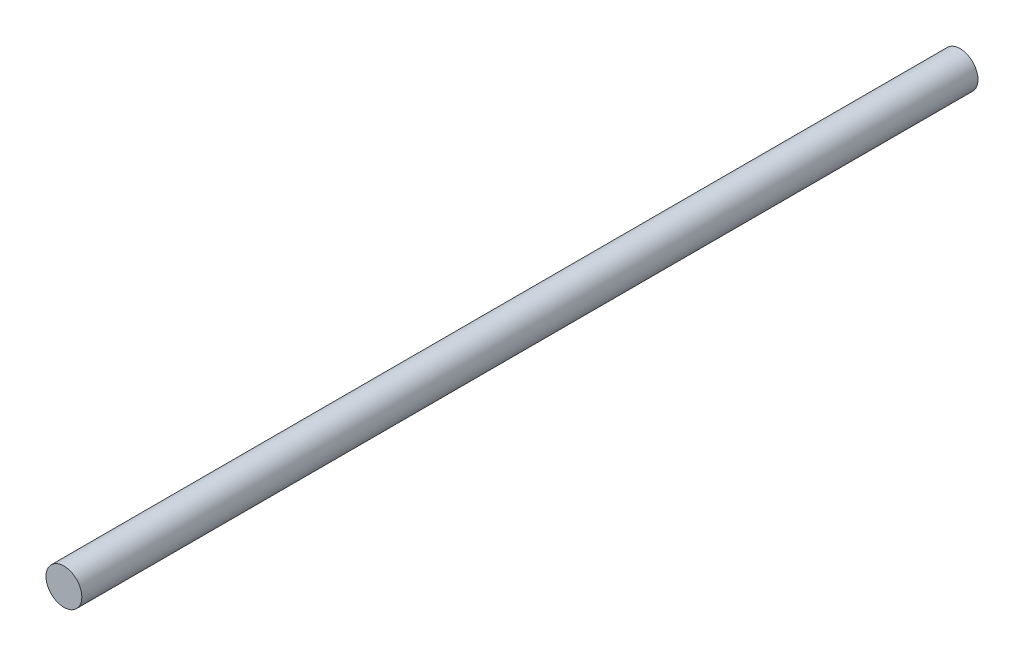
from build123d import *

# Parameters (mm, degrees)
SKETCH_1_R      = 2
EXTRUDE_1_DEPTH = 100


with BuildPart() as part:
    # 草图1 → 凸台-拉伸1 (new body)
    with BuildSketch(Plane.XY):
        Circle(SKETCH_1_R)
    extrude(amount=EXTRUDE_1_DEPTH)


solid = part.part
